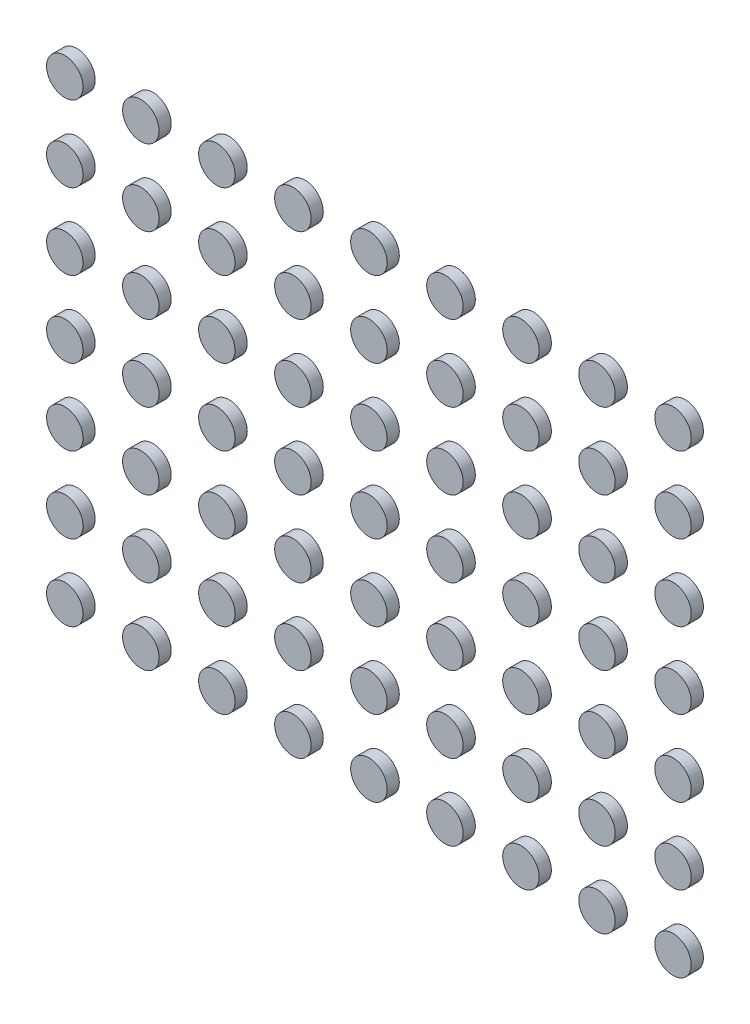
from build123d import *

# Parameters (mm, degrees)
SKETCH_1_R               = 0.6
EXTRUDE_1_DEPTH          = 0.4
PATTERN_LINEAR_1_COUNT   = 9
PATTERN_LINEAR_1_PITCH   = 2.5
PATTERN_LINEAR_1_2_COUNT = 7
PATTERN_LINEAR_1_2_PITCH = 2.5


with BuildPart() as part:
    # 草图1 → 凸台-拉伸1 (new body)
    with BuildSketch(Plane.XY):
        Circle(SKETCH_1_R)
    extrude(amount=EXTRUDE_1_DEPTH)


with BuildPart() as pattern_linear_1_1:
    # 阵列(线性)1: pattern copy
    add(part.part.moved(Location(Vector(1, 0, 0) * (1 * PATTERN_LINEAR_1_PITCH))))


with BuildPart() as pattern_linear_1_2:
    # 阵列(线性)1: pattern copy
    add(part.part.moved(Location(Vector(1, 0, 0) * (2 * PATTERN_LINEAR_1_PITCH))))


with BuildPart() as pattern_linear_1_3:
    # 阵列(线性)1: pattern copy
    add(part.part.moved(Location(Vector(1, 0, 0) * (3 * PATTERN_LINEAR_1_PITCH))))


with BuildPart() as pattern_linear_1_4:
    # 阵列(线性)1: pattern copy
    add(part.part.moved(Location(Vector(1, 0, 0) * (4 * PATTERN_LINEAR_1_PITCH))))


with BuildPart() as pattern_linear_1_5:
    # 阵列(线性)1: pattern copy
    add(part.part.moved(Location(Vector(1, 0, 0) * (5 * PATTERN_LINEAR_1_PITCH))))


with BuildPart() as pattern_linear_1_6:
    # 阵列(线性)1: pattern copy
    add(part.part.moved(Location(Vector(1, 0, 0) * (6 * PATTERN_LINEAR_1_PITCH))))


with BuildPart() as pattern_linear_1_7:
    # 阵列(线性)1: pattern copy
    add(part.part.moved(Location(Vector(1, 0, 0) * (7 * PATTERN_LINEAR_1_PITCH))))


with BuildPart() as pattern_linear_1_8:
    # 阵列(线性)1: pattern copy
    add(part.part.moved(Location(Vector(1, 0, 0) * (8 * PATTERN_LINEAR_1_PITCH))))


with BuildPart() as pattern_linear_1_2_1:
    # Pattern Linear 1 2: pattern copy
    add(part.part.moved(Location(Vector(0, 1, 0) * (1 * PATTERN_LINEAR_1_2_PITCH))))


with BuildPart() as pattern_linear_1_2_2:
    # Pattern Linear 1 2: pattern copy
    add(part.part.moved(Location(Vector(0, 1, 0) * (2 * PATTERN_LINEAR_1_2_PITCH))))


with BuildPart() as pattern_linear_1_2_3:
    # Pattern Linear 1 2: pattern copy
    add(part.part.moved(Location(Vector(0, 1, 0) * (3 * PATTERN_LINEAR_1_2_PITCH))))


with BuildPart() as pattern_linear_1_2_4:
    # Pattern Linear 1 2: pattern copy
    add(part.part.moved(Location(Vector(0, 1, 0) * (4 * PATTERN_LINEAR_1_2_PITCH))))


with BuildPart() as pattern_linear_1_2_5:
    # Pattern Linear 1 2: pattern copy
    add(part.part.moved(Location(Vector(0, 1, 0) * (5 * PATTERN_LINEAR_1_2_PITCH))))


with BuildPart() as pattern_linear_1_2_6:
    # Pattern Linear 1 2: pattern copy
    add(part.part.moved(Location(Vector(0, 1, 0) * (6 * PATTERN_LINEAR_1_2_PITCH))))


with BuildPart() as pattern_linear_1_2_7:
    # Pattern Linear 1 2: pattern copy
    add(pattern_linear_1_1.part.moved(Location(Vector(0, 1, 0) * (1 * PATTERN_LINEAR_1_2_PITCH))))


with BuildPart() as pattern_linear_1_2_8:
    # Pattern Linear 1 2: pattern copy
    add(pattern_linear_1_1.part.moved(Location(Vector(0, 1, 0) * (2 * PATTERN_LINEAR_1_2_PITCH))))


with BuildPart() as pattern_linear_1_2_9:
    # Pattern Linear 1 2: pattern copy
    add(pattern_linear_1_1.part.moved(Location(Vector(0, 1, 0) * (3 * PATTERN_LINEAR_1_2_PITCH))))


with BuildPart() as pattern_linear_1_2_10:
    # Pattern Linear 1 2: pattern copy
    add(pattern_linear_1_1.part.moved(Location(Vector(0, 1, 0) * (4 * PATTERN_LINEAR_1_2_PITCH))))


with BuildPart() as pattern_linear_1_2_11:
    # Pattern Linear 1 2: pattern copy
    add(pattern_linear_1_1.part.moved(Location(Vector(0, 1, 0) * (5 * PATTERN_LINEAR_1_2_PITCH))))


with BuildPart() as pattern_linear_1_2_12:
    # Pattern Linear 1 2: pattern copy
    add(pattern_linear_1_1.part.moved(Location(Vector(0, 1, 0) * (6 * PATTERN_LINEAR_1_2_PITCH))))


with BuildPart() as pattern_linear_1_2_13:
    # Pattern Linear 1 2: pattern copy
    add(pattern_linear_1_2.part.moved(Location(Vector(0, 1, 0) * (1 * PATTERN_LINEAR_1_2_PITCH))))


with BuildPart() as pattern_linear_1_2_14:
    # Pattern Linear 1 2: pattern copy
    add(pattern_linear_1_2.part.moved(Location(Vector(0, 1, 0) * (2 * PATTERN_LINEAR_1_2_PITCH))))


with BuildPart() as pattern_linear_1_2_15:
    # Pattern Linear 1 2: pattern copy
    add(pattern_linear_1_2.part.moved(Location(Vector(0, 1, 0) * (3 * PATTERN_LINEAR_1_2_PITCH))))


with BuildPart() as pattern_linear_1_2_16:
    # Pattern Linear 1 2: pattern copy
    add(pattern_linear_1_2.part.moved(Location(Vector(0, 1, 0) * (4 * PATTERN_LINEAR_1_2_PITCH))))


with BuildPart() as pattern_linear_1_2_17:
    # Pattern Linear 1 2: pattern copy
    add(pattern_linear_1_2.part.moved(Location(Vector(0, 1, 0) * (5 * PATTERN_LINEAR_1_2_PITCH))))


with BuildPart() as pattern_linear_1_2_18:
    # Pattern Linear 1 2: pattern copy
    add(pattern_linear_1_2.part.moved(Location(Vector(0, 1, 0) * (6 * PATTERN_LINEAR_1_2_PITCH))))


with BuildPart() as pattern_linear_1_2_19:
    # Pattern Linear 1 2: pattern copy
    add(pattern_linear_1_3.part.moved(Location(Vector(0, 1, 0) * (1 * PATTERN_LINEAR_1_2_PITCH))))


with BuildPart() as pattern_linear_1_2_20:
    # Pattern Linear 1 2: pattern copy
    add(pattern_linear_1_3.part.moved(Location(Vector(0, 1, 0) * (2 * PATTERN_LINEAR_1_2_PITCH))))


with BuildPart() as pattern_linear_1_2_21:
    # Pattern Linear 1 2: pattern copy
    add(pattern_linear_1_3.part.moved(Location(Vector(0, 1, 0) * (3 * PATTERN_LINEAR_1_2_PITCH))))


with BuildPart() as pattern_linear_1_2_22:
    # Pattern Linear 1 2: pattern copy
    add(pattern_linear_1_3.part.moved(Location(Vector(0, 1, 0) * (4 * PATTERN_LINEAR_1_2_PITCH))))


with BuildPart() as pattern_linear_1_2_23:
    # Pattern Linear 1 2: pattern copy
    add(pattern_linear_1_3.part.moved(Location(Vector(0, 1, 0) * (5 * PATTERN_LINEAR_1_2_PITCH))))


with BuildPart() as pattern_linear_1_2_24:
    # Pattern Linear 1 2: pattern copy
    add(pattern_linear_1_3.part.moved(Location(Vector(0, 1, 0) * (6 * PATTERN_LINEAR_1_2_PITCH))))


with BuildPart() as pattern_linear_1_2_25:
    # Pattern Linear 1 2: pattern copy
    add(pattern_linear_1_4.part.moved(Location(Vector(0, 1, 0) * (1 * PATTERN_LINEAR_1_2_PITCH))))


with BuildPart() as pattern_linear_1_2_26:
    # Pattern Linear 1 2: pattern copy
    add(pattern_linear_1_4.part.moved(Location(Vector(0, 1, 0) * (2 * PATTERN_LINEAR_1_2_PITCH))))


with BuildPart() as pattern_linear_1_2_27:
    # Pattern Linear 1 2: pattern copy
    add(pattern_linear_1_4.part.moved(Location(Vector(0, 1, 0) * (3 * PATTERN_LINEAR_1_2_PITCH))))


with BuildPart() as pattern_linear_1_2_28:
    # Pattern Linear 1 2: pattern copy
    add(pattern_linear_1_4.part.moved(Location(Vector(0, 1, 0) * (4 * PATTERN_LINEAR_1_2_PITCH))))


with BuildPart() as pattern_linear_1_2_29:
    # Pattern Linear 1 2: pattern copy
    add(pattern_linear_1_4.part.moved(Location(Vector(0, 1, 0) * (5 * PATTERN_LINEAR_1_2_PITCH))))


with BuildPart() as pattern_linear_1_2_30:
    # Pattern Linear 1 2: pattern copy
    add(pattern_linear_1_4.part.moved(Location(Vector(0, 1, 0) * (6 * PATTERN_LINEAR_1_2_PITCH))))


with BuildPart() as pattern_linear_1_2_31:
    # Pattern Linear 1 2: pattern copy
    add(pattern_linear_1_5.part.moved(Location(Vector(0, 1, 0) * (1 * PATTERN_LINEAR_1_2_PITCH))))


with BuildPart() as pattern_linear_1_2_32:
    # Pattern Linear 1 2: pattern copy
    add(pattern_linear_1_5.part.moved(Location(Vector(0, 1, 0) * (2 * PATTERN_LINEAR_1_2_PITCH))))


with BuildPart() as pattern_linear_1_2_33:
    # Pattern Linear 1 2: pattern copy
    add(pattern_linear_1_5.part.moved(Location(Vector(0, 1, 0) * (3 * PATTERN_LINEAR_1_2_PITCH))))


with BuildPart() as pattern_linear_1_2_34:
    # Pattern Linear 1 2: pattern copy
    add(pattern_linear_1_5.part.moved(Location(Vector(0, 1, 0) * (4 * PATTERN_LINEAR_1_2_PITCH))))


with BuildPart() as pattern_linear_1_2_35:
    # Pattern Linear 1 2: pattern copy
    add(pattern_linear_1_5.part.moved(Location(Vector(0, 1, 0) * (5 * PATTERN_LINEAR_1_2_PITCH))))


with BuildPart() as pattern_linear_1_2_36:
    # Pattern Linear 1 2: pattern copy
    add(pattern_linear_1_5.part.moved(Location(Vector(0, 1, 0) * (6 * PATTERN_LINEAR_1_2_PITCH))))


with BuildPart() as pattern_linear_1_2_37:
    # Pattern Linear 1 2: pattern copy
    add(pattern_linear_1_6.part.moved(Location(Vector(0, 1, 0) * (1 * PATTERN_LINEAR_1_2_PITCH))))


with BuildPart() as pattern_linear_1_2_38:
    # Pattern Linear 1 2: pattern copy
    add(pattern_linear_1_6.part.moved(Location(Vector(0, 1, 0) * (2 * PATTERN_LINEAR_1_2_PITCH))))


with BuildPart() as pattern_linear_1_2_39:
    # Pattern Linear 1 2: pattern copy
    add(pattern_linear_1_6.part.moved(Location(Vector(0, 1, 0) * (3 * PATTERN_LINEAR_1_2_PITCH))))


with BuildPart() as pattern_linear_1_2_40:
    # Pattern Linear 1 2: pattern copy
    add(pattern_linear_1_6.part.moved(Location(Vector(0, 1, 0) * (4 * PATTERN_LINEAR_1_2_PITCH))))


with BuildPart() as pattern_linear_1_2_41:
    # Pattern Linear 1 2: pattern copy
    add(pattern_linear_1_6.part.moved(Location(Vector(0, 1, 0) * (5 * PATTERN_LINEAR_1_2_PITCH))))


with BuildPart() as pattern_linear_1_2_42:
    # Pattern Linear 1 2: pattern copy
    add(pattern_linear_1_6.part.moved(Location(Vector(0, 1, 0) * (6 * PATTERN_LINEAR_1_2_PITCH))))


with BuildPart() as pattern_linear_1_2_43:
    # Pattern Linear 1 2: pattern copy
    add(pattern_linear_1_7.part.moved(Location(Vector(0, 1, 0) * (1 * PATTERN_LINEAR_1_2_PITCH))))


with BuildPart() as pattern_linear_1_2_44:
    # Pattern Linear 1 2: pattern copy
    add(pattern_linear_1_7.part.moved(Location(Vector(0, 1, 0) * (2 * PATTERN_LINEAR_1_2_PITCH))))


with BuildPart() as pattern_linear_1_2_45:
    # Pattern Linear 1 2: pattern copy
    add(pattern_linear_1_7.part.moved(Location(Vector(0, 1, 0) * (3 * PATTERN_LINEAR_1_2_PITCH))))


with BuildPart() as pattern_linear_1_2_46:
    # Pattern Linear 1 2: pattern copy
    add(pattern_linear_1_7.part.moved(Location(Vector(0, 1, 0) * (4 * PATTERN_LINEAR_1_2_PITCH))))


with BuildPart() as pattern_linear_1_2_47:
    # Pattern Linear 1 2: pattern copy
    add(pattern_linear_1_7.part.moved(Location(Vector(0, 1, 0) * (5 * PATTERN_LINEAR_1_2_PITCH))))


with BuildPart() as pattern_linear_1_2_48:
    # Pattern Linear 1 2: pattern copy
    add(pattern_linear_1_7.part.moved(Location(Vector(0, 1, 0) * (6 * PATTERN_LINEAR_1_2_PITCH))))


with BuildPart() as pattern_linear_1_2_49:
    # Pattern Linear 1 2: pattern copy
    add(pattern_linear_1_8.part.moved(Location(Vector(0, 1, 0) * (1 * PATTERN_LINEAR_1_2_PITCH))))


with BuildPart() as pattern_linear_1_2_50:
    # Pattern Linear 1 2: pattern copy
    add(pattern_linear_1_8.part.moved(Location(Vector(0, 1, 0) * (2 * PATTERN_LINEAR_1_2_PITCH))))


with BuildPart() as pattern_linear_1_2_51:
    # Pattern Linear 1 2: pattern copy
    add(pattern_linear_1_8.part.moved(Location(Vector(0, 1, 0) * (3 * PATTERN_LINEAR_1_2_PITCH))))


with BuildPart() as pattern_linear_1_2_52:
    # Pattern Linear 1 2: pattern copy
    add(pattern_linear_1_8.part.moved(Location(Vector(0, 1, 0) * (4 * PATTERN_LINEAR_1_2_PITCH))))


with BuildPart() as pattern_linear_1_2_53:
    # Pattern Linear 1 2: pattern copy
    add(pattern_linear_1_8.part.moved(Location(Vector(0, 1, 0) * (5 * PATTERN_LINEAR_1_2_PITCH))))


with BuildPart() as pattern_linear_1_2_54:
    # Pattern Linear 1 2: pattern copy
    add(pattern_linear_1_8.part.moved(Location(Vector(0, 1, 0) * (6 * PATTERN_LINEAR_1_2_PITCH))))


solid = Compound([part.part, pattern_linear_1_1.part, pattern_linear_1_2.part, pattern_linear_1_3.part, pattern_linear_1_4.part, pattern_linear_1_5.part, pattern_linear_1_6.part, pattern_linear_1_7.part, pattern_linear_1_8.part, pattern_linear_1_2_1.part, pattern_linear_1_2_2.part, pattern_linear_1_2_3.part, pattern_linear_1_2_4.part, pattern_linear_1_2_5.part, pattern_linear_1_2_6.part, pattern_linear_1_2_7.part, pattern_linear_1_2_8.part, pattern_linear_1_2_9.part, pattern_linear_1_2_10.part, pattern_linear_1_2_11.part, pattern_linear_1_2_12.part, pattern_linear_1_2_13.part, pattern_linear_1_2_14.part, pattern_linear_1_2_15.part, pattern_linear_1_2_16.part, pattern_linear_1_2_17.part, pattern_linear_1_2_18.part, pattern_linear_1_2_19.part, pattern_linear_1_2_20.part, pattern_linear_1_2_21.part, pattern_linear_1_2_22.part, pattern_linear_1_2_23.part, pattern_linear_1_2_24.part, pattern_linear_1_2_25.part, pattern_linear_1_2_26.part, pattern_linear_1_2_27.part, pattern_linear_1_2_28.part, pattern_linear_1_2_29.part, pattern_linear_1_2_30.part, pattern_linear_1_2_31.part, pattern_linear_1_2_32.part, pattern_linear_1_2_33.part, pattern_linear_1_2_34.part, pattern_linear_1_2_35.part, pattern_linear_1_2_36.part, pattern_linear_1_2_37.part, pattern_linear_1_2_38.part, pattern_linear_1_2_39.part, pattern_linear_1_2_40.part, pattern_linear_1_2_41.part, pattern_linear_1_2_42.part, pattern_linear_1_2_43.part, pattern_linear_1_2_44.part, pattern_linear_1_2_45.part, pattern_linear_1_2_46.part, pattern_linear_1_2_47.part, pattern_linear_1_2_48.part, pattern_linear_1_2_49.part, pattern_linear_1_2_50.part, pattern_linear_1_2_51.part, pattern_linear_1_2_52.part, pattern_linear_1_2_53.part, pattern_linear_1_2_54.part])
